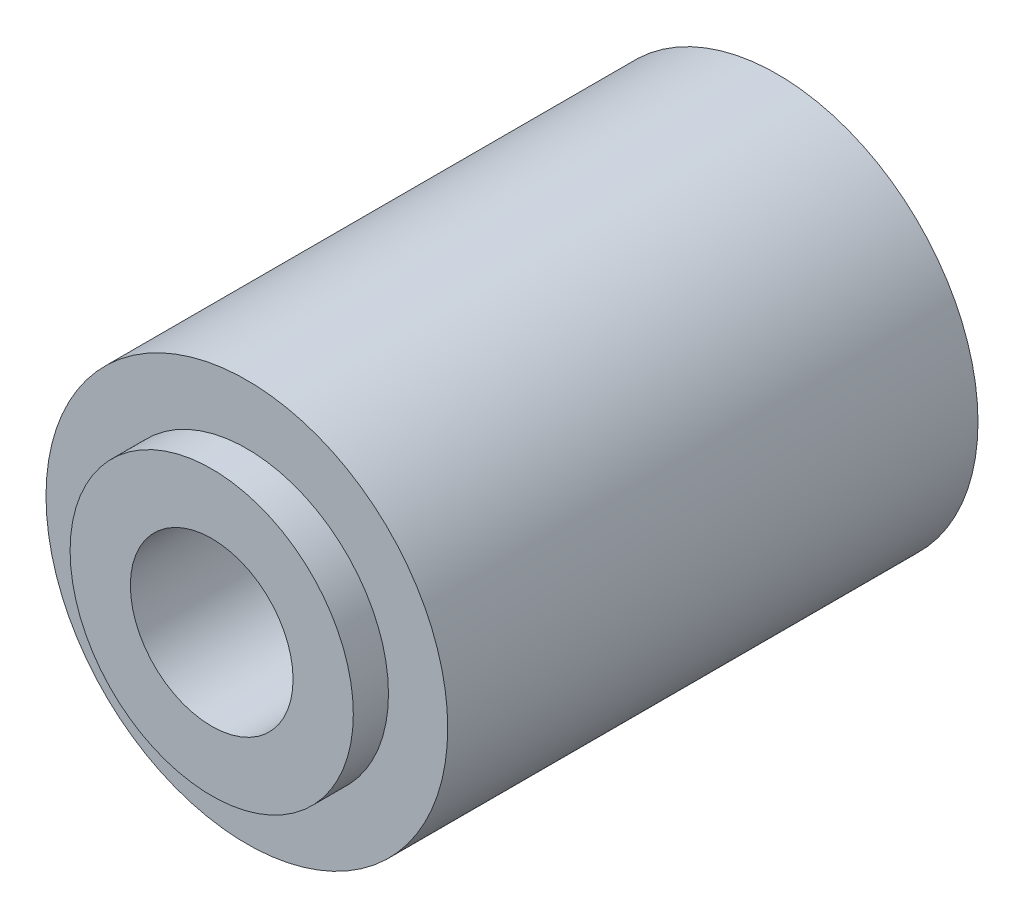
from build123d import *

# Parameters (mm, degrees)
CROQUIS1_R              = 10
CROQUIS1_R_2            = 4.05
SALIENTE_EXTRUIR1_DEPTH = 26.4
CROQUIS2_R              = 7.05
CROQUIS2_R_2            = 4.05
SALIENTE_EXTRUIR2_DEPTH = 1.75
CROQUIS3_R              = 7.05
CROQUIS3_R_2            = 4.05
SALIENTE_EXTRUIR3_DEPTH = 1.75


with BuildPart() as part:
    # Croquis1 → Saliente-Extruir1 (new body)
    with BuildSketch(Plane.XY):
        Circle(CROQUIS1_R)
        Circle(CROQUIS1_R_2, mode=Mode.SUBTRACT)
    extrude(amount=SALIENTE_EXTRUIR1_DEPTH)

    # Croquis2 → Saliente-Extruir2 (add)
    with BuildSketch(Plane.XY.offset(26.4)):
        Circle(CROQUIS2_R)
        Circle(CROQUIS2_R_2, mode=Mode.SUBTRACT)
    extrude(amount=SALIENTE_EXTRUIR2_DEPTH)

    # Croquis3 → Saliente-Extruir3 (add)
    with BuildSketch(Plane(origin=(0, 0, 0), x_dir=(-1, 0, 0), z_dir=(0, 0, -1))):
        Circle(CROQUIS3_R)
        Circle(CROQUIS3_R_2, mode=Mode.SUBTRACT)
    extrude(amount=SALIENTE_EXTRUIR3_DEPTH)


solid = part.part
